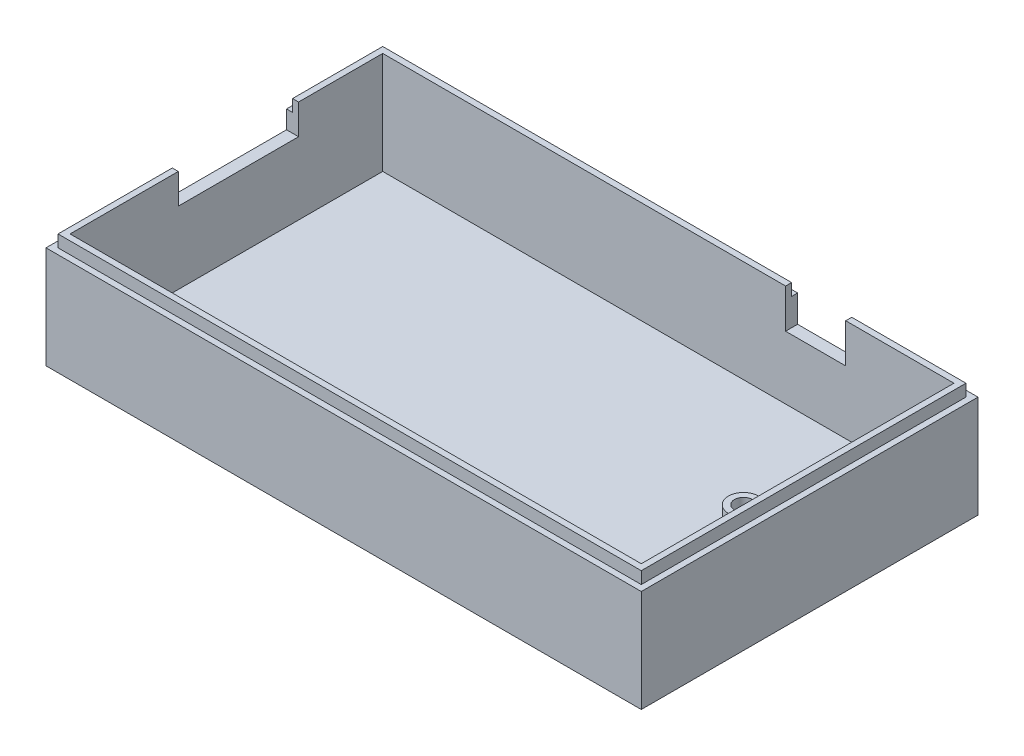
from build123d import *

# Parameters (mm, degrees)
SKETCH1_R                         = 2.5
BOSS_EXTRUDE1_DEPTH               = 8
SKETCH1_3_W                       = 99
SKETCH1_3_H                       = 56
SKETCH1_3_W_2                     = 97
SKETCH1_3_H_2                     = 54
SKETCH1_3_W_3                     = 95
SKETCH1_3_H_3                     = 52
SKETCH1_3_R                       = 2.5
BOSS_EXTRUDE2_DEPTH               = 2
SKETCH1_5_W                       = 99
SKETCH1_5_H                       = 56
SKETCH1_5_W_2                     = 97
SKETCH1_5_H_2                     = 54
SKETCH1_5_W_3                     = 95
SKETCH1_5_H_3                     = 52
BOSS_EXTRUDE4_DEPTH               = 15
SKETCH1_6_W                       = 97
SKETCH1_6_H                       = 54
SKETCH1_6_W_2                     = 95
SKETCH1_6_H_2                     = 52
BOSS_EXTRUDE5_DEPTH               = 17
SKETCH4_W                         = 1.5
SKETCH4_H                         = 2
F_3_0_3_DIAMETER_HOLE1_AT_2_COUNT = 2
F_3_0_3_DIAMETER_HOLE1_AT_2_PITCH = 98.412397593
SKETCH8_W                         = 1.5
SKETCH8_H                         = 10
CUT_EXTRUDE1_START                = -2
SKETCH9_W                         = 20
SKETCH9_H                         = 5
CUT_EXTRUDE1_DEPTH                = 2
CUT_EXTRUDE2_START                = -2
SKETCH10_W                        = 10
SKETCH10_H                        = 6.51132948
CUT_EXTRUDE2_DEPTH                = 2


with BuildPart() as part:
    # Sketch1 → Boss-Extrude1 (new body)
    with BuildSketch(Plane(origin=(0, 0, 0), x_dir=(1, 0, 0), z_dir=(0, 1, 0))):
        with Locations(Location((38.5, 0, 0), (0, 0, 270))):
            Circle(SKETCH1_R)
    extrude(amount=BOSS_EXTRUDE1_DEPTH)

    # Sketch8 → Ø3.0 (3) Diameter Hole2 (revolve, cut)
    with BuildSketch(Plane(origin=(38.5, 8, 0), x_dir=(0, 0, 1), z_dir=(1, 0, 0))):
        with Locations((0.75, 5)):
            Rectangle(SKETCH8_W, SKETCH8_H)
    revolve(axis=Axis((38.5, 14.35, 0), (0, -1, 0)), mode=Mode.SUBTRACT)


with BuildPart() as body_2:
    # Sketch1_3 → Boss-Extrude2 (new body)
    with BuildSketch(Plane(origin=(0, 0, 0), x_dir=(1, 0, 0), z_dir=(0, 1, 0))):
        Rectangle(SKETCH1_3_W, SKETCH1_3_H)
        Rectangle(SKETCH1_3_W_2, SKETCH1_3_H_2, mode=Mode.SUBTRACT)
        Rectangle(SKETCH1_3_W_2, SKETCH1_3_H_2)
        Rectangle(SKETCH1_3_W_3, SKETCH1_3_H_3, mode=Mode.SUBTRACT)
        Rectangle(SKETCH1_3_W_3, SKETCH1_3_H_3)
        with Locations(Location((38.5, 0, 0), (0, 0, 270))):
            Circle(SKETCH1_3_R, mode=Mode.SUBTRACT)
    extrude(amount=-BOSS_EXTRUDE2_DEPTH)

    # Sketch1_5 → Boss-Extrude4 (add)
    with BuildSketch(Plane(origin=(0, 0, 0), x_dir=(1, 0, 0), z_dir=(0, 1, 0))):
        Rectangle(SKETCH1_5_W, SKETCH1_5_H)
        Rectangle(SKETCH1_5_W_2, SKETCH1_5_H_2, mode=Mode.SUBTRACT)
        Rectangle(SKETCH1_5_W_2, SKETCH1_5_H_2)
        Rectangle(SKETCH1_5_W_3, SKETCH1_5_H_3, mode=Mode.SUBTRACT)
    extrude(amount=BOSS_EXTRUDE4_DEPTH)

    # Sketch1_6 → Boss-Extrude5 (add)
    with BuildSketch(Plane(origin=(0, 0, 0), x_dir=(1, 0, 0), z_dir=(0, 1, 0))):
        Rectangle(SKETCH1_6_W, SKETCH1_6_H)
        Rectangle(SKETCH1_6_W_2, SKETCH1_6_H_2, mode=Mode.SUBTRACT)
    extrude(amount=BOSS_EXTRUDE5_DEPTH)

    # Sketch4 → Ø3.0 (3) Diameter Hole1 (revolve, cut)
    with BuildSketch(Plane(origin=(-44.5, 0, 21), x_dir=(0, 0, 1), z_dir=(1, 0, 0))):
        with Locations((0.75, 1)):
            Rectangle(SKETCH4_W, SKETCH4_H)
    f_3_0_3_diameter_hole1 = revolve(axis=Axis((-44.5, 6.35, 21), (0, -1, 0)), mode=Mode.SUBTRACT)

    # Ø3.0 (3) Diameter Hole1 at 2: Ø3.0 (3) Diameter Hole1 ×2
    with Locations(*[Vector(0.9043576030744216, 0, -0.42677549808006415) * (i * F_3_0_3_DIAMETER_HOLE1_AT_2_PITCH) for i in range(1, F_3_0_3_DIAMETER_HOLE1_AT_2_COUNT)]):
        add(f_3_0_3_diameter_hole1, mode=Mode.SUBTRACT)

    # Sketch9 → Cut-Extrude1 (cut)
    with BuildSketch(Plane.ZY.offset(49.5).offset(CUT_EXTRUDE1_START)):
        with Locations((-2, 14.5)):
            Rectangle(SKETCH9_W, SKETCH9_H)
    extrude(amount=CUT_EXTRUDE1_DEPTH, mode=Mode.SUBTRACT)

    # Sketch10 → Cut-Extrude2 (cut)
    with BuildSketch(Plane(origin=(0, 0, -28), x_dir=(-1, 0, 0), z_dir=(0, 0, -1)).offset(CUT_EXTRUDE2_START)):
        with Locations((-24.5, 13.74433526)):
            Rectangle(SKETCH10_W, SKETCH10_H)
    extrude(amount=CUT_EXTRUDE2_DEPTH, mode=Mode.SUBTRACT)


solid = Compound([part.part, body_2.part])
